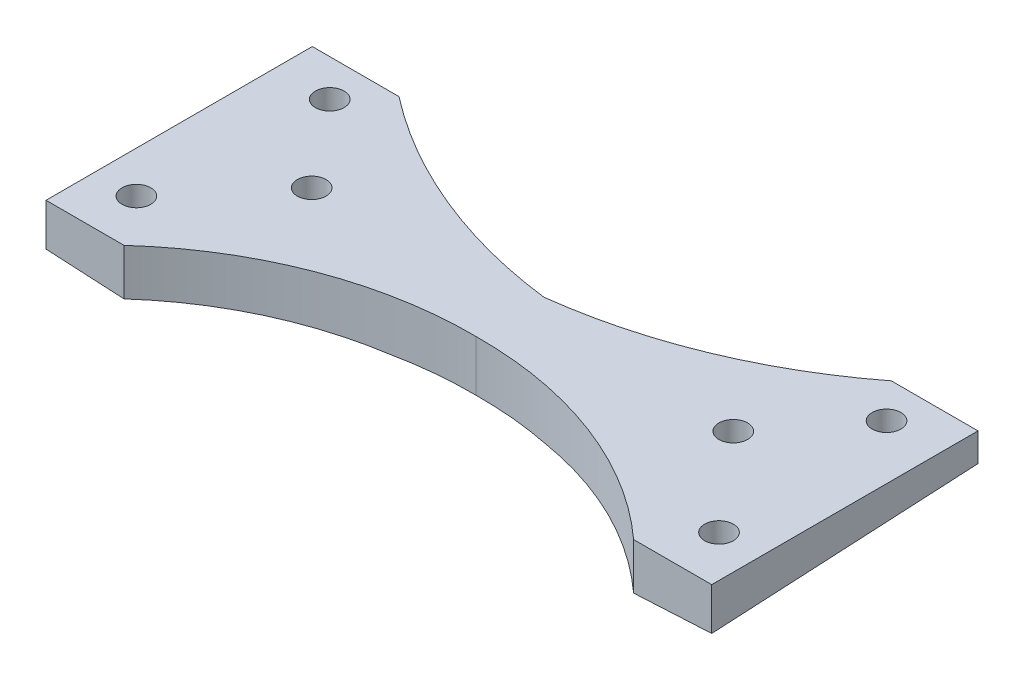
from build123d import *

# Parameters (mm, degrees)
SKETCH1_W                = 31.75
SKETCH1_H                = 4.859095613
BOSS_EXTRUDE1_DEPTH      = 12.7
BOSS_EXTRUDE1_DEPTH_BACK = 12.7
SKETCH3_R                = 1.3716
CUT_EXTRUDE1_DEPTH       = 10.16


with BuildPart() as part:
    # Sketch1 → Boss-Extrude1 (new, two sides)
    with BuildSketch(Plane.XY) as boss_extrude1_sk:
        with Locations((-15.875, 46.294481234)):
            Rectangle(SKETCH1_W, SKETCH1_H)
    extrude(amount=BOSS_EXTRUDE1_DEPTH)
    extrude(boss_extrude1_sk.sketch, amount=-BOSS_EXTRUDE1_DEPTH_BACK)

    # Sketch3 → Cut-Extrude1 (cut)
    with BuildSketch(Plane(origin=(0, 48.72402904, 0), x_dir=(1, 0, 0), z_dir=(0, 1, 0))):
        with Locations(Location((-20.105647723, 0.999384842, 0), (0, 0, 180))):
            Circle(SKETCH3_R)
        with Locations(Location((-26.555704526, 9.169971692, 0), (0, 0, 180))):
            Circle(SKETCH3_R)
        with Locations(Location((-27.786476371, -8.040568412, 0), (0, 0, 180))):
            Circle(SKETCH3_R)
        with BuildLine():
            Line((0, 3.041554035), (0, 12.7))
            Line((0, 12.7), (-23.483825151, 12.7))
            ThreePointArc((-23.483825151, 12.7), (-12.393492486, 6.286506758), (0, 3.041554035))
        make_face()
        with BuildLine():
            Line((0, -3.441610433), (0, -12.7))
            Line((0, -12.7), (-24.301693504, -12.7))
            ThreePointArc((-24.301693504, -12.7), (-13.024999481, -5.776303398), (0, -3.441610433))
        make_face()
    extrude(amount=-CUT_EXTRUDE1_DEPTH, mode=Mode.SUBTRACT)

    # SurfaceCut1
    split(bisect_by=Plane(origin=(2.277212667, 43.451806158, 2.28033779), x_dir=(0.9986332910992534, -0.052192408999060975, -0.0027390420129575405), z_dir=(0.05226423163382398, 0.9972609476841369, 0.0523359562429442)), keep=Keep.TOP)

    # Mirror1: part across plane


with BuildPart() as part_1:
    add(part.part)
    add(part.part.mirror(Plane(origin=(0, 48.72402904, -12.7), x_dir=(0, 0, 1), z_dir=(-1, 0, 0))))


solid = part_1.part
